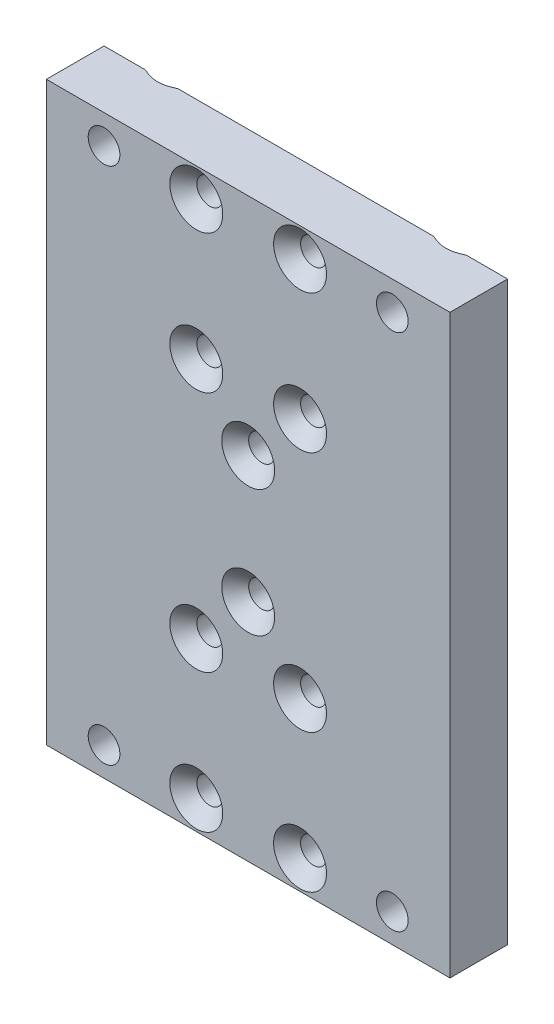
from build123d import *

# Parameters (mm, degrees)
SKETCH1_W                                            = 70
SKETCH1_H                                            = 100
BOSS_EXTRUDE1_DEPTH                                  = 10
SKETCH2_R                                            = 2.5
CUT_EXTRUDE1_DEPTH                                   = 11
SKETCH3_R                                            = 1.5
CUT_EXTRUDE2_DEPTH                                   = 11
SKETCH5_R                                            = 2
CUT_EXTRUDE4_DEPTH                                   = 11
CSK_FOR_M4_SOCKET_COUNTERSUNK_HEAD_SCREW_D           = 4.5
CSK_FOR_M4_SOCKET_COUNTERSUNK_HEAD_SCREW_CSINK_D     = 9.18
CSK_FOR_M4_SOCKET_COUNTERSUNK_HEAD_SCREW_CSINK_ANGLE = 90
CSK_FOR_M5_SOCKET_COUNTERSUNK_HEAD_SCREW_D           = 5.5
CSK_FOR_M5_SOCKET_COUNTERSUNK_HEAD_SCREW_CSINK_D     = 11.47
CSK_FOR_M5_SOCKET_COUNTERSUNK_HEAD_SCREW_CSINK_ANGLE = 90


with BuildPart() as part:
    # Sketch1 → Boss-Extrude1 (new body)
    with BuildSketch(Plane.XY):
        Rectangle(SKETCH1_W, SKETCH1_H)
    extrude(amount=BOSS_EXTRUDE1_DEPTH)

    # Sketch2 → Cut-Extrude1 (cut, through all)
    with BuildSketch(Plane(origin=(0, 0, 0), x_dir=(-1, 0, 0), z_dir=(0, 0, -1))):
        with Locations((-25, 45)):
            Circle(SKETCH2_R)
        with Locations((25, 45)):
            Circle(SKETCH2_R)
        with Locations((-25, -45)):
            Circle(SKETCH2_R)
        with Locations((25, -45)):
            Circle(SKETCH2_R)
    extrude(amount=-CUT_EXTRUDE1_DEPTH, mode=Mode.SUBTRACT)

    # Sketch3 → Cut-Extrude2 (cut, through all)
    with BuildSketch(Plane(origin=(0, 0, 0), x_dir=(-1, 0, 0), z_dir=(0, 0, -1))):
        with Locations((9, 21)):
            Circle(SKETCH3_R)
        with Locations((9, 45)):
            Circle(SKETCH3_R)
        with Locations((-9, 21)):
            Circle(SKETCH3_R)
        with Locations((-9, 45)):
            Circle(SKETCH3_R)
        with Locations((9, -45)):
            Circle(SKETCH3_R)
        with Locations((9, -21)):
            Circle(SKETCH3_R)
        with Locations((-9, -45)):
            Circle(SKETCH3_R)
        with Locations((-9, -21)):
            Circle(SKETCH3_R)
    extrude(amount=-CUT_EXTRUDE2_DEPTH, mode=Mode.SUBTRACT)

    # Sketch5 → Cut-Extrude4 (cut, through all)
    with BuildSketch(Plane.XY.offset(10)):
        with Locations((0, -11)):
            Circle(SKETCH5_R)
        with Locations((0, 11)):
            Circle(SKETCH5_R)
    extrude(amount=-CUT_EXTRUDE4_DEPTH, mode=Mode.SUBTRACT)

    # CSK for M4 socket countersunk head screw1 (through all)
    with Locations(Plane.XY.offset(10)):
        with Locations((-9, 45), (9, 45), (9, 21), (-9, 21), (0, 11), (0, -11), (9, -21), (-9, -21), (-9, -45), (9, -45)):
            CounterSinkHole(CSK_FOR_M4_SOCKET_COUNTERSUNK_HEAD_SCREW_D / 2, CSK_FOR_M4_SOCKET_COUNTERSUNK_HEAD_SCREW_CSINK_D / 2, counter_sink_angle=CSK_FOR_M4_SOCKET_COUNTERSUNK_HEAD_SCREW_CSINK_ANGLE)

    # CSK for M5 socket countersunk head screw2 (through all)
    with Locations(Plane(origin=(0, 0, 0), x_dir=(-1, 0, 0), z_dir=(0, 0, -1))):
        with Locations((-25, 45), (25, 45), (25, -45), (-25, -45)):
            CounterSinkHole(CSK_FOR_M5_SOCKET_COUNTERSUNK_HEAD_SCREW_D / 2, CSK_FOR_M5_SOCKET_COUNTERSUNK_HEAD_SCREW_CSINK_D / 2, counter_sink_angle=CSK_FOR_M5_SOCKET_COUNTERSUNK_HEAD_SCREW_CSINK_ANGLE)


solid = part.part
